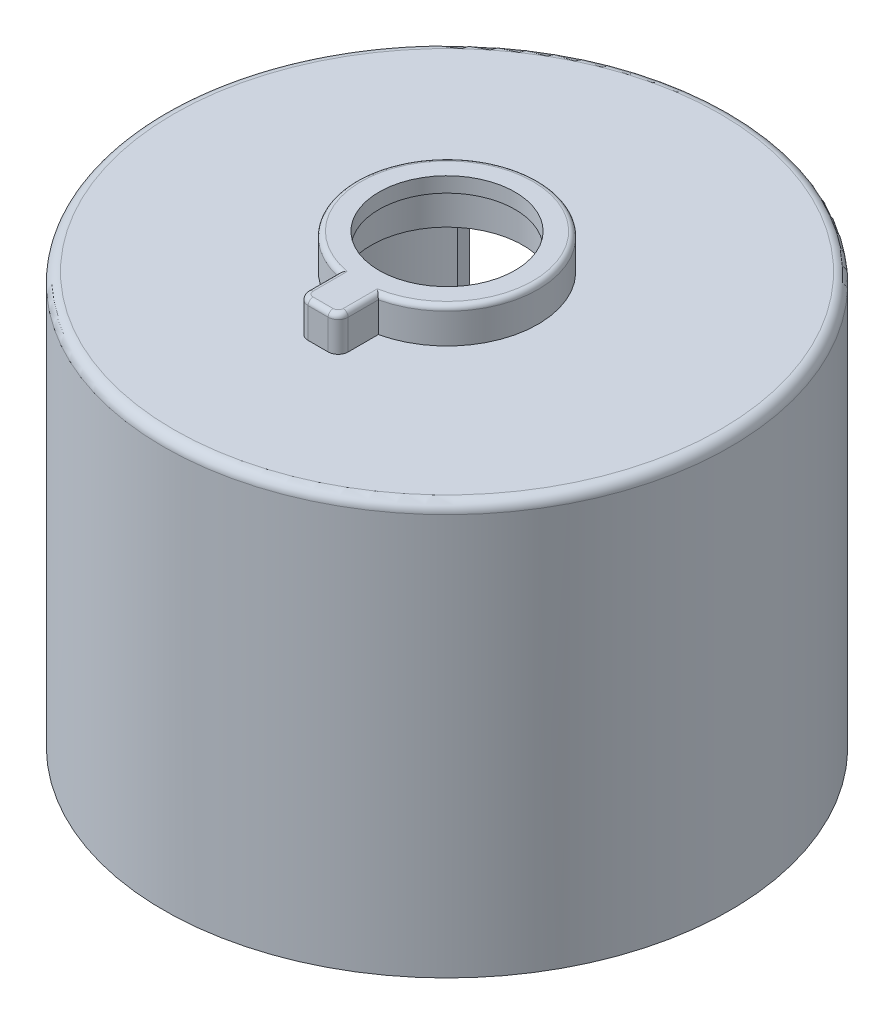
from build123d import *

# Parameters (mm, degrees)
SKETCH1_R           = 28.25
BOSS_EXTRUDE1_DEPTH = 41
SKETCH2_R           = 26.75
CUT_EXTRUDE1_DEPTH  = 39.5
SKETCH3_R           = 9.075
SKETCH3_R_2         = 7.575
BOSS_EXTRUDE2_DEPTH = 3.5
SKETCH4_R           = 9.075
SKETCH4_R_2         = 6.775
BOSS_EXTRUDE3_DEPTH = 1.5
SKETCH5_R           = 7.575
CUT_EXTRUDE2_DEPTH  = 1.5
SKETCH6_W           = 4
SKETCH6_H           = 4
BOSS_EXTRUDE4_DEPTH = 3.5
CUT_EXTRUDE3_DEPTH  = 37.5
FILLET1_R           = 1
FILLET1_2_R         = 0.5


with BuildPart() as part:
    # Sketch1 → Boss-Extrude1 (new body)
    with BuildSketch(Plane(origin=(0, 0, 0), x_dir=(1, 0, 0), z_dir=(0, 1, 0))):
        Circle(SKETCH1_R)
    extrude(amount=BOSS_EXTRUDE1_DEPTH)

    # Sketch2 → Cut-Extrude1 (cut)
    with BuildSketch(Plane.XZ):
        Circle(SKETCH2_R)
    extrude(amount=-CUT_EXTRUDE1_DEPTH, mode=Mode.SUBTRACT)

    # Sketch3 → Boss-Extrude2 (add)
    with BuildSketch(Plane(origin=(0, 41, 0), x_dir=(1, 0, 0), z_dir=(0, 1, 0))):
        Circle(SKETCH3_R)
        Circle(SKETCH3_R_2, mode=Mode.SUBTRACT)
    extrude(amount=BOSS_EXTRUDE2_DEPTH)

    # Sketch4 → Boss-Extrude3 (add)
    with BuildSketch(Plane(origin=(0, 44.5, 0), x_dir=(1, 0, 0), z_dir=(0, 1, 0))):
        Circle(SKETCH4_R)
        Circle(SKETCH4_R_2, mode=Mode.SUBTRACT)
    extrude(amount=-BOSS_EXTRUDE3_DEPTH)

    # Sketch5 → Cut-Extrude2 (cut)
    with BuildSketch(Plane(origin=(0, 41, 0), x_dir=(1, 0, 0), z_dir=(0, 1, 0))):
        Circle(SKETCH5_R)
    extrude(amount=-CUT_EXTRUDE2_DEPTH, mode=Mode.SUBTRACT)

    # Sketch6 → Boss-Extrude4 (add)
    with BuildSketch(Plane(origin=(0, 44.5, 0), x_dir=(1, 0, 0), z_dir=(0, 1, 0))):
        with Locations((0, -10.851871271)):
            Rectangle(SKETCH6_W, SKETCH6_H)
    extrude(amount=-BOSS_EXTRUDE4_DEPTH)

    # Sketch8 → Cut-Extrude3 (cut)
    with BuildSketch(Plane.XZ):
        with BuildLine():
            Line((-18.827156573, -21.06182982), (-16.65, -12.936570875))
            Line((-16.65, -12.936570875), (-16.65, 12.95))
            Line((-16.65, 12.95), (16.65, 12.95))
            Line((16.65, 12.95), (16.65, -12.936570875))
            Line((16.65, -12.936570875), (18.827156573, -21.06182982))
            ThreePointArc((18.827156573, -21.06182982), (0, -28.25), (-18.827156573, -21.06182982))
        make_face()
    extrude(amount=-CUT_EXTRUDE3_DEPTH, mode=Mode.SUBTRACT)

    # Fillet1
    fillet1_edges = [part.edges().sort_by_distance(p)[0] for p in [
        (-2, 42.75, 12.851871271),
        (2, 42.75, 12.851871271),
        (-28.25, 41, 0),
    ]]
    fillet(fillet1_edges, radius=FILLET1_R)

    # Fillet1 2
    fillet1_2_edges = [part.edges().sort_by_distance(p)[0] for p in [
        (0, 44.5, -9.075),
        (-2, 44.5, 10.851871271),
        (0, 44.5, 12.851871271),
        (2, 44.5, 10.851871271),
    ]]
    fillet(fillet1_2_edges, radius=FILLET1_2_R)


solid = part.part
